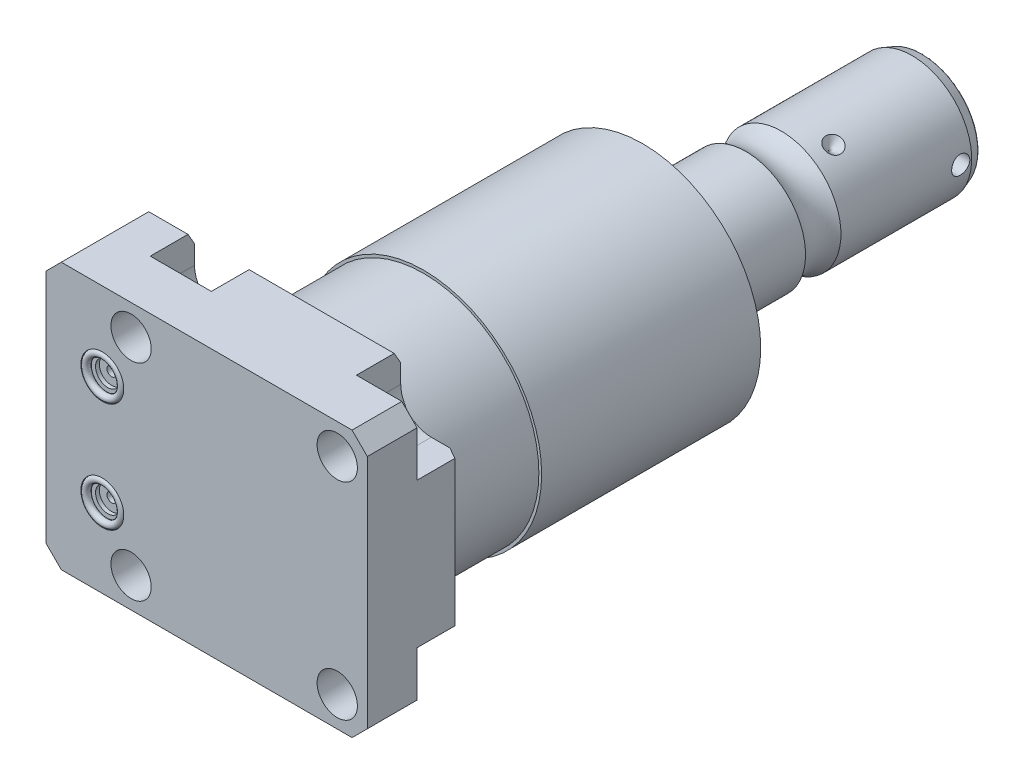
from build123d import *

# Parameters (mm, degrees)
SKETCH1_W            = 85.4964
SKETCH1_H            = 70.866
EXTRUDE1_DEPTH       = 25.019
SKETCH2_R            = 5.3594
CUT_EXTRUDE1_DEPTH   = 27.5209
LPATTERN1_COUNT      = 2
LPATTERN1_PITCH      = 54.864
LPATTERN1_COUNT_DIR2 = 2
LPATTERN1_PITCH_DIR2 = 54.864
CUT_EXTRUDE2_DEPTH   = 11.7856
SKETCH6_R            = 5.7023
CUT_EXTRUDE3_DEPTH   = 1.4478
SKETCH7_R            = 3.2512
CUT_EXTRUDE4_DEPTH   = 1.016
SKETCH8_R            = 1.2446
CUT_EXTRUDE5_DEPTH   = 11.9888
SKETCH9_R            = 0.9271
CHAMFER1_SIZE        = 4.064
CHAMFER2_SIZE        = 3.0226
CHAMFER2_SIZE2       = 1.745098924
SKETCH14_R           = 31.3944
EXTRUDE2_DEPTH       = 86.995
SKETCH15_OUTSIDE_W   = 119.1
SKETCH15_OUTSIDE_H   = 104.47
SKETCH15_OUTSIDE_R   = 30.6578
CUT_EXTRUDE9_DEPTH   = 25.4
SKETCH19_R           = 7.112
EXTRUDE3_DEPTH       = 1.524
SKETCH20_R           = 12.954
SKETCH20_R_2         = 12.573
CUT_EXTRUDE10_DEPTH  = 0.254
CUT_EXTRUDE11_DEPTH  = 8.001
CIRPATTERN1_COUNT    = 3
SKETCH23_W           = 3.81
SKETCH23_H           = 2.413
FILLET1_R            = 0.635


with BuildPart() as part:
    # Sketch1 → Extrude1 (new body)
    with BuildSketch(Plane.XY):
        with Locations((-7.3152, 0)):
            Rectangle(SKETCH1_W, SKETCH1_H)
    extrude(amount=EXTRUDE1_DEPTH)

    # Sketch2 → Cut-Extrude1 (cut)
    with BuildSketch(Plane(origin=(0, 0, 0), x_dir=(-1, 0, 0), z_dir=(0, 0, -1))):
        with Locations((-27.432, -27.432)):
            Circle(SKETCH2_R)
    cut_extrude1 = extrude(amount=-CUT_EXTRUDE1_DEPTH, mode=Mode.SUBTRACT)

    # LPattern1: Cut-Extrude1 2 × 2
    with Locations(*[(-j * LPATTERN1_PITCH_DIR2, i * LPATTERN1_PITCH, 0) for i in range(LPATTERN1_COUNT) for j in range(LPATTERN1_COUNT_DIR2) if (i, j) != (0, 0)]):
        add(cut_extrude1, mode=Mode.SUBTRACT)

    # Sketch3 → Cut-Extrude2 (cut)
    with BuildSketch(Plane(origin=(0, 0, 0), x_dir=(-1, 0, 0), z_dir=(0, 0, -1))):
        with BuildLine():
            Line((-27.432, -19.304), (-35.433, -19.304))
            Line((-35.433, -19.304), (-35.433, -35.433))
            Line((-35.433, -35.433), (-19.304, -35.433))
            Line((-19.304, -35.433), (-19.304, -27.432))
            ThreePointArc((-19.304, -27.432), (-21.684636083, -21.684636083), (-27.432, -19.304))
        make_face()
        with BuildLine():
            Line((-35.433, 19.304), (-35.433, 35.433))
            Line((-35.433, 35.433), (-19.304, 35.433))
            Line((-19.304, 35.433), (-19.304, 27.432))
            ThreePointArc((-19.304, 27.432), (-21.684636083, 21.684636083), (-27.432, 19.304))
            Line((-27.432, 19.304), (-35.433, 19.304))
        make_face()
        with BuildLine():
            Line((19.304, 35.433), (19.304, 27.432))
            ThreePointArc((19.304, 27.432), (27.432, 19.304), (35.56, 27.432))
            Line((35.56, 27.432), (35.56, 35.433))
            Line((35.56, 35.433), (19.304, 35.433))
        make_face()
        with BuildLine():
            Line((35.56, -35.433), (19.304, -35.433))
            Line((19.304, -35.433), (19.304, -27.432))
            ThreePointArc((19.304, -27.432), (27.432, -19.304), (35.56, -27.432))
            Line((35.56, -27.432), (35.56, -35.433))
        make_face()
    extrude(amount=-CUT_EXTRUDE2_DEPTH, mode=Mode.SUBTRACT)

    # S2D0007 → Cut-Revolve1 (revolve, cut)
    with BuildSketch(Plane(origin=(-55.5498, -13.0048, 12.5222), x_dir=(0, 1, 0), z_dir=(0, 0, 1)), mode=Mode.PRIVATE) as cut_revolve1_sk:
        Polygon((0, -5.4864), (10.4775, -5.4864), (10.4775, -5.7404), (6.1849, -5.7404), (5.642306865, -8.2931), (4.9784, -8.957006865), (4.9784, -19.7104), (0, -19.7104), align=None)
    cut_revolve1 = revolve(cut_revolve1_sk.sketch.rotate(Axis((-35.077219214, -13.0048, 12.5222), (-1, 0, 0)), 90), axis=Axis((-35.077219214, -13.0048, 12.5222), (-1, 0, 0)), mode=Mode.SUBTRACT)  # turned: the seam where the file's is

    # Mirror1: Cut-Revolve1 across plane
    add(cut_revolve1.mirror(Plane.ZX), mode=Mode.SUBTRACT)

    # Sketch6 → Cut-Extrude3 (cut)
    with BuildSketch(Plane.XY.offset(25.019)):
        with Locations((-35.0774, -14.5288)):
            Circle(SKETCH6_R)
        with Locations((-35.0774, 14.5288)):
            Circle(SKETCH6_R)
    extrude(amount=-CUT_EXTRUDE3_DEPTH, mode=Mode.SUBTRACT)

    # Sketch7 → Cut-Extrude4 (cut)
    with BuildSketch(Plane.XY.offset(23.5712)):
        with Locations((-35.0774, 14.5288)):
            Circle(SKETCH7_R)
        with Locations((-35.0774, -14.5288)):
            Circle(SKETCH7_R)
    extrude(amount=-CUT_EXTRUDE4_DEPTH, mode=Mode.SUBTRACT)

    # Sketch8 → Cut-Extrude5 (cut)
    with BuildSketch(Plane.XY.offset(22.5552)):
        with Locations((-35.0774, 14.5288)):
            Circle(SKETCH8_R)
        with Locations((-35.0774, -14.5288)):
            Circle(SKETCH8_R)
    extrude(amount=-CUT_EXTRUDE5_DEPTH, mode=Mode.SUBTRACT)

    # Chamfer1
    chamfer1_edges = [part.edges().sort_by_distance(p)[0] for p in [
        (-50.0634, 35.433, 12.5095),
        (35.433, 35.433, 18.4023),
        (35.433, -35.433, 18.4023),
        (-50.0634, -35.433, 12.5095),
    ]]
    chamfer(chamfer1_edges, length=CHAMFER1_SIZE)

    # Chamfer2
    chamfer2_edges = [part.edges().sort_by_distance(p)[0] for p in [
        (-40.7797, -35.433, 0),
        (35.433, 0, 0),
        (0, 35.433, 0),
        (-40.7797, 35.433, 0),
        (0, -35.433, 0),
    ]]
    chamfer2_side = [part.faces().sort_by_distance(p)[0] for p in [
        (-8.721448678, 0, 0),
    ]]
    chamfer(chamfer2_edges, length=CHAMFER2_SIZE, length2=CHAMFER2_SIZE2, reference=chamfer2_side[0])

    # Sketch14 → Extrude2 (add)
    with BuildSketch(Plane(origin=(0, 0, 0), x_dir=(-1, 0, 0), z_dir=(0, 0, -1))):
        with Locations(Location((0, 0, 0), (0, 0, 140.520960584))):  # turned: the seam where the file's is
            Circle(SKETCH14_R)
    extrude(amount=EXTRUDE2_DEPTH)

    # Sketch15 outside → Cut-Extrude9 (cut)
    with BuildSketch(Plane(origin=(0, 0, 0), x_dir=(-1, 0, 0), z_dir=(0, 0, -1))):
        with Locations((7.315, 0)):
            Rectangle(SKETCH15_OUTSIDE_W, SKETCH15_OUTSIDE_H)
        Circle(SKETCH15_OUTSIDE_R, mode=Mode.SUBTRACT)
    extrude(amount=CUT_EXTRUDE9_DEPTH, mode=Mode.SUBTRACT)

    # Sketch16 → Cut-Revolve3 (revolve, cut)
    with BuildSketch(Plane(origin=(0, 0, 0), x_dir=(0, 0, 1), z_dir=(1, 0, 0)), mode=Mode.PRIVATE) as cut_revolve3_sk:
        Polygon((-86.995, 19.05), (-83.687327989, 31.3944), (-86.995, 31.3944), align=None)
    revolve(cut_revolve3_sk.sketch.rotate(Axis((0, 0, -96.582204284), (0, 0, 1)), 270), axis=Axis((0, 0, -96.582204284), (0, 0, 1)), mode=Mode.SUBTRACT)  # turned: the seam where the file's is

    # Sketch17 → Revolve3 (revolve)
    with BuildSketch(Plane(origin=(0, 0, 0), x_dir=(0, 0, 1), z_dir=(1, 0, 0)), mode=Mode.PRIVATE) as revolve3_sk:
        with BuildLine():
            Line((-86.995, 0), (-86.995, 15.875))
            Line((-86.995, 15.875), (-111.14230643, 15.875))
            ThreePointArc((-111.14230643, 15.875), (-115.8494, 14.3256), (-120.55649357, 15.875))
            Line((-120.55649357, 15.875), (-155.3464, 15.875))
            Line((-155.3464, 15.875), (-158.2674, 14.811842946))
            Line((-158.2674, 14.811842946), (-158.2674, 0))
            Line((-158.2674, 0), (-86.995, 0))
        make_face()
    revolve(revolve3_sk.sketch.rotate(Axis((0, 0, -180.9369), (0, 0, 1)), 270), axis=Axis((0, 0, -180.9369), (0, 0, 1)))  # turned: the seam where the file's is

    # Sketch19 → Extrude3 (add)
    with BuildSketch(Plane.ZY.offset(49.8094)):
        with Locations(Location((12.5222, -13.0048, 0), (0, 0, 180))):  # turned: the seam where the file's is
            Circle(SKETCH19_R)
    extrude(amount=EXTRUDE3_DEPTH)

    # Sketch20 → Cut-Extrude10 (cut)
    with BuildSketch(Plane(origin=(0, 0, -158.2674), x_dir=(-1, 0, 0), z_dir=(0, 0, -1))):
        Circle(SKETCH20_R)
        Circle(SKETCH20_R_2, mode=Mode.SUBTRACT)
    extrude(amount=-CUT_EXTRUDE10_DEPTH, mode=Mode.SUBTRACT)

    # Sketch21 → Cut-Extrude11 (cut)
    with BuildSketch(Plane(origin=(0, 0, -158.2674), x_dir=(-1, 0, 0), z_dir=(0, 0, -1))):
        Polygon((4.619379504, 0), (2.309689752, 4.0005), (-2.309689752, 4.0005), (-4.619379504, 0), (-2.309689752, -4.0005), (2.309689752, -4.0005), align=None)
    extrude(amount=-CUT_EXTRUDE11_DEPTH, mode=Mode.SUBTRACT)

    # Sketch22 → Cut-Revolve4 (revolve, cut)
    with BuildSketch(Plane(origin=(0, 0, 0), x_dir=(1, 0, 0), z_dir=(0, 1, 0)), mode=Mode.PRIVATE) as cut_revolve4_sk:
        Polygon((-15.875, 128.9304), (-15.875, 126.5174), (-13.462, 126.5174), align=None)
    cut_revolve4 = revolve(cut_revolve4_sk.sketch.rotate(Axis((-21.668802649, 0, -126.5174), (1, 0, 0)), 180), axis=Axis((-21.668802649, 0, -126.5174), (1, 0, 0)), mode=Mode.SUBTRACT)  # turned: the seam where the file's is

    # CirPattern1: Cut-Revolve4 ×3 about axis
    cirpattern1_axis = Axis((0, 0, -180.9369), (0, 0, -1))
    for i in range(1, CIRPATTERN1_COUNT):
        add(cut_revolve4.rotate(cirpattern1_axis, i * 360 / CIRPATTERN1_COUNT), mode=Mode.SUBTRACT)

    # Sketch23 → Cut-Revolve5 (revolve, cut)
    with BuildSketch(Plane(origin=(0, 0, 0), x_dir=(1, 0, 0), z_dir=(0, 1, 0)), mode=Mode.PRIVATE) as cut_revolve5_sk:
        with Locations((13.97, 153.6319)):
            Rectangle(SKETCH23_W, SKETCH23_H)
    revolve(cut_revolve5_sk.sketch.rotate(Axis((-15.875, 0, -152.4254), (1, 0, 0)), 180), axis=Axis((-15.875, 0, -152.4254), (1, 0, 0)), mode=Mode.SUBTRACT)  # turned: the seam where the file's is

    # Fillet1
    fillet1_edges = [part.edges().sort_by_distance(p)[0] for p in [
        (14.811842946, 0, -158.2674),
    ]]
    fillet(fillet1_edges, radius=FILLET1_R)


with BuildPart() as body_2:
    # Sketch9 → Revolve1 (revolve)
    with BuildSketch(Plane(origin=(-41.656, -14.5288, 23.5712), x_dir=(1, 0, 0), z_dir=(0, 1, 0))):
        with Locations((11.3538, -0.9271)):
            Circle(SKETCH9_R)
    revolve(axis=Axis((-35.0774, -14.5288, 25.51811), (0, 0, -1)))


with BuildPart() as body_3:
    # Mirror2: mirrored copy
    add(body_2.part.mirror(Plane.ZX))


solid = Compound([part.part, body_2.part, body_3.part])
